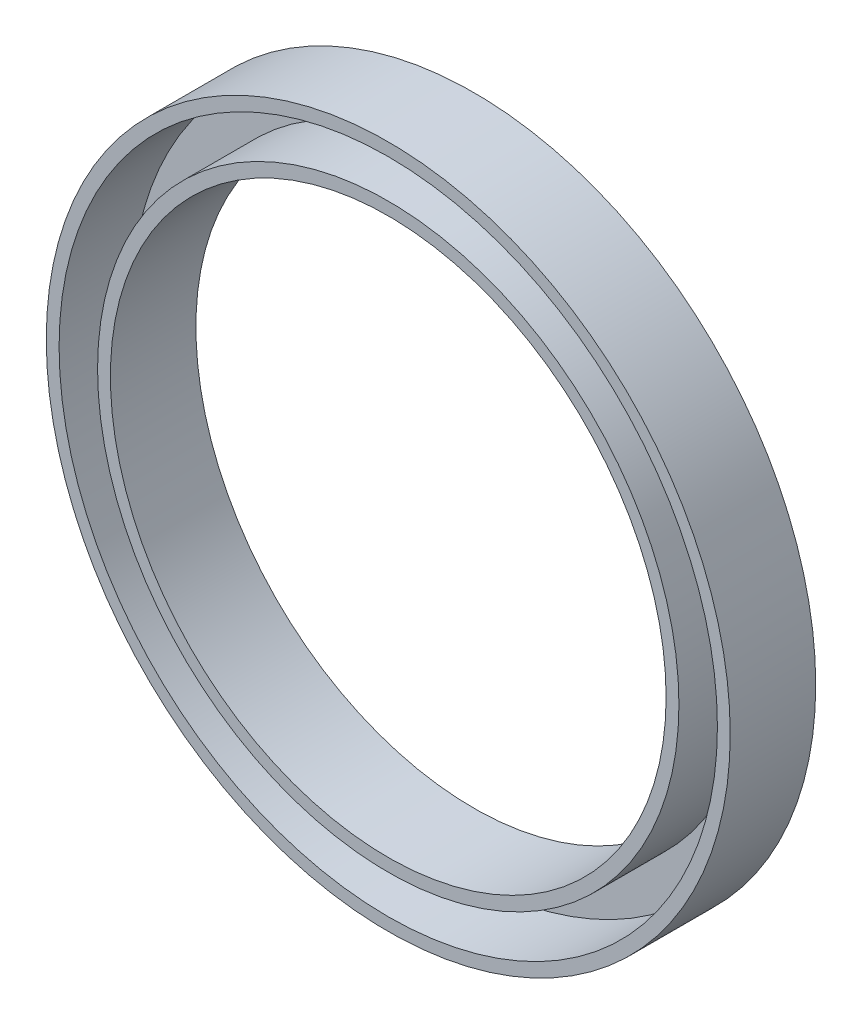
from build123d import *

# Parameters (mm, degrees)
SKETCH_1_R      = 40
SKETCH_1_R_2    = 32.5
EXTRUDE_1_DEPTH = 10
SHELL_1_T       = -1.5


with BuildPart() as part:
    # 草图1 → 凸台-拉伸1 (new body)
    with BuildSketch(Plane.XY):
        Circle(SKETCH_1_R)
        Circle(SKETCH_1_R_2, mode=Mode.SUBTRACT)
    extrude(amount=EXTRUDE_1_DEPTH)

    # 抽壳1
    shell_1_openings = [part.faces().sort_by_distance(p)[0] for p in [
        (-38.86862915, 0, 10),
    ]]
    offset(amount=SHELL_1_T, openings=shell_1_openings, kind=Kind.INTERSECTION)


solid = part.part
